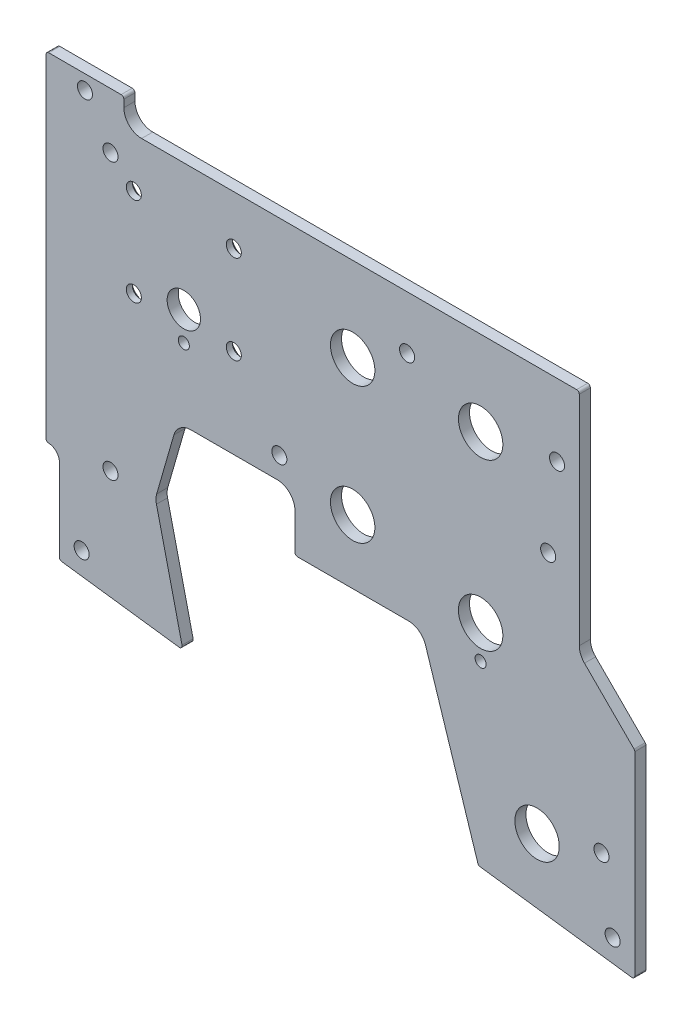
from build123d import *

# Parameters (mm, degrees)
BOSS_EXTRUDE1_DEPTH                       = 3.175
F_6_CLEARANCE_HOLE1_D                     = 4.3053
SKETCH4_R                                 = 6.35
SKETCH4_R_2                               = 1.5875
SKETCH4_R_3                               = 4.7625
CUT_EXTRUDE1_DEPTH                        = 4.175
CSK_FOR_6_FLAT_HEAD_MACHINE_SCREW_2_COUNT = 2
CSK_FOR_6_FLAT_HEAD_MACHINE_SCREW_2_PITCH = 28.575
CSK_FOR_6_FLAT_HEAD_MACHINE_SCREW_3_COUNT = 2
CSK_FOR_6_FLAT_HEAD_MACHINE_SCREW_3_PITCH = 38.232062788
CSK_FOR_6_FLAT_HEAD_MACHINE_SCREW_4_COUNT = 2
CSK_FOR_6_FLAT_HEAD_MACHINE_SCREW_4_PITCH = 25.4
F_0_CLEARANCE_HOLE1_D                     = 1.8542
F_1_8_0_125_DIAMETER_HOLE1_D              = 3.175


with BuildPart() as part:
    # Sketch1 → Boss-Extrude1 (new body)
    with BuildSketch(Plane.XY):
        with BuildLine():
            Line((3.809986215, -91.884500325), (3.80998361, -115.403340545))
            ThreePointArc((3.80998361, -115.403340545), (3.999081622, -115.90576205), (4.472522544, -116.158821571))
            Line((4.472522544, -116.158821571), (38.023104274, -120.5758443))
            ThreePointArc((38.023104274, -120.5758443), (38.687459595, -120.33177166), (38.864463259, -119.646491316))
            Line((38.864463259, -119.646491316), (31.544635998, -88.413376307))
            ThreePointArc((31.544635998, -88.413376307), (31.412233483, -87.126289027), (31.609278422, -85.84750156))
            Line((31.609278422, -85.84750156), (36.533410401, -68.760772014))
            ThreePointArc((36.533410401, -68.760772014), (38.360231081, -66.108400459), (41.414754107, -65.0875))
            Line((41.414754107, -65.0875), (66.039990754, -65.0875))
            ThreePointArc((66.039990754, -65.0875), (69.632093202, -66.575397552), (71.119990754, -70.1675))
            Line((71.119990754, -70.1675), (71.119990754, -80.518))
            ThreePointArc((71.119990754, -80.518), (71.343175387, -81.056815367), (71.881990754, -81.28))
            Line((71.881990754, -81.28), (103.612235862, -81.28))
            ThreePointArc((103.612235862, -81.28), (106.604490402, -82.25478225), (108.448399818, -84.805034342))
            Line((108.448399818, -84.805034342), (123.423319929, -131.379161885))
            ThreePointArc((123.423319929, -131.379161885), (123.660593225, -131.731025839), (124.049283564, -131.901398021))
            Line((124.049283564, -131.901398021), (167.413526593, -137.610408921))
            ThreePointArc((167.413526593, -137.610408921), (168.015409063, -137.42782987), (168.274987552, -136.854927937))
            Line((168.274987552, -136.854927937), (168.274987552, -81.303553632))
            ThreePointArc((168.274987552, -81.303553632), (168.216983776, -81.011948907), (168.051802995, -80.764738341))
            Line((168.051802995, -80.764738341), (153.88788809, -66.600819412))
            ThreePointArc((153.88788809, -66.600819412), (152.786682817, -64.952748811), (152.399991049, -63.008717113))
            Line((152.399991049, -63.008717113), (152.399999892, -0.762021595))
            ThreePointArc((152.399999892, -0.762021595), (152.176815316, -0.223206231), (151.638, -2.1541e-05))
            Line((151.638, -2.1541e-05), (27.305, -3.804e-06))
            ThreePointArc((27.305, -3.804e-06), (23.712898123, 1.487894033), (22.22500087, 5.079996121))
            Line((22.22500087, 5.079996121), (22.225001755, 7.175496897))
            ThreePointArc((22.225001755, 7.175496897), (22.001816945, 7.7143128), (21.463001073, 7.937498421))
            Line((21.463001073, 7.937498421), (0.762001075, 7.937499892))
            ThreePointArc((0.762001075, 7.937499892), (0.223185691, 7.714315297), (1.021e-06, 7.175499945))
            Line((1.021e-06, 7.175499945), (-1.2342e-05, -87.949548922))
            ThreePointArc((-1.2342e-05, -87.949548922), (0.214550622, -88.479602508), (0.737406874, -88.711153328))
            ThreePointArc((0.737406874, -88.711153328), (2.915974038, -89.675944454), (3.809986215, -91.884500325))
        make_face()
    extrude(amount=-BOSS_EXTRUDE1_DEPTH)

    # #6 Clearance Hole1 (through all)
    with Locations(Plane(origin=(0, 0, -3.175), x_dir=(-1, 0, 0), z_dir=(0, 0, -1))):
        with Locations((-11.112500541, 3.81), (-18.414998872, -7.937503157), (-103.187497835, -15.240014658), (-143.510001128, -44.450020387), (-158.750001128, -111.125021649), (-18.414987678, -86.741003157), (-66.674991751, -58.7375), (-10.16, -110.502822935), (-146.049997068, -20.637520747), (-161.924987552, -130.483035149)):
            Hole(F_6_CLEARANCE_HOLE1_D / 2)

    # Sketch4 → Cut-Extrude1 (cut, through all)
    with BuildSketch(Plane(origin=(0, 0, -3.175), x_dir=(-1, 0, 0), z_dir=(0, 0, -1))):
        with Locations((-140.334987552, -115.57)):
            Circle(SKETCH4_R)
        with Locations((-124.205996572, -71.437521424)):
            Circle(SKETCH4_R)
        with Locations((-87.63, -62.992021649)):
            Circle(SKETCH4_R)
        with Locations((-87.63, -24.130021649)):
            Circle(SKETCH4_R)
        with Locations((-124.205996572, -24.130021649)):
            Circle(SKETCH4_R)
        with Locations((-124.205996572, -80.962521424)):
            Circle(SKETCH4_R_2)
        with Locations((-39.36999484, -36.322003157)):
            Circle(SKETCH4_R_3)
    extrude(amount=-CUT_EXTRUDE1_DEPTH, mode=Mode.SUBTRACT)

    # Sketch5 → CSK for #6 Flat Head Machine Screw (100)1 (revolve, cut)
    with BuildSketch(Plane(origin=(53.65749484, -14.097003157, -3.175), x_dir=(0, 1, 0), z_dir=(1, 0, 0))):
        Polygon((0, 0), (0, 3.175), (2.15265, 3.175), (2.15265, 1.420893136), (3.8460045, 0), align=None)
    csk_for_6_flat_head_machine_screw_100 = revolve(axis=Axis((53.65749484, -14.097003157, -9.525), (0, 0, 1)), mode=Mode.SUBTRACT)

    # CSK for _6 Flat Head Machine Screw _ 2: CSK for #6 Flat Head Machine Screw (100)1 ×2
    with Locations(*[(-i * CSK_FOR_6_FLAT_HEAD_MACHINE_SCREW_2_PITCH, 0, 0) for i in range(1, CSK_FOR_6_FLAT_HEAD_MACHINE_SCREW_2_COUNT)]):
        add(csk_for_6_flat_head_machine_screw_100, mode=Mode.SUBTRACT)

    # CSK for _6 Flat Head Machine Screw _ 3: CSK for #6 Flat Head Machine Screw (100)1 ×2
    with Locations(*[Vector(-0.747409319, -0.664363839, 0) * (i * CSK_FOR_6_FLAT_HEAD_MACHINE_SCREW_3_PITCH) for i in range(1, CSK_FOR_6_FLAT_HEAD_MACHINE_SCREW_3_COUNT)]):
        add(csk_for_6_flat_head_machine_screw_100, mode=Mode.SUBTRACT)

    # CSK for _6 Flat Head Machine Screw _ 4: CSK for #6 Flat Head Machine Screw (100)1 ×2
    with Locations(*[(0, -i * CSK_FOR_6_FLAT_HEAD_MACHINE_SCREW_4_PITCH, 0) for i in range(1, CSK_FOR_6_FLAT_HEAD_MACHINE_SCREW_4_COUNT)]):
        add(csk_for_6_flat_head_machine_screw_100, mode=Mode.SUBTRACT)

    # #0 Clearance Hole1 (through all)
    with Locations(Plane(origin=(0, 0, -9.525), x_dir=(-1, 0, 0), z_dir=(0, 0, -1))):
        with Locations((-39.36999484, -44.577003157)):
            Hole(F_0_CLEARANCE_HOLE1_D / 2)

    # 1/8 (0.125) Diameter Hole1 (through all)
    with Locations(Plane.XY):
        with Locations((39.36999484, -44.577003157)):
            Hole(F_1_8_0_125_DIAMETER_HOLE1_D / 2)


solid = part.part
